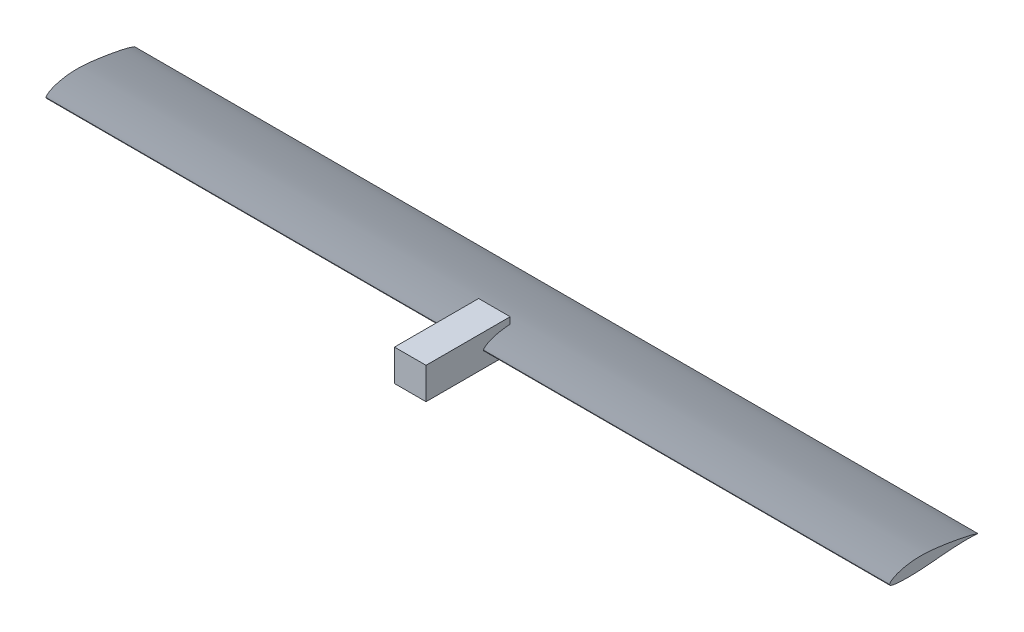
from build123d import *

# Parameters (mm, degrees)
SKETCH1_W                = 76.2
SKETCH1_H                = 76.2
BOSS_EXTRUDE1_DEPTH      = 203.2
BOSS_EXTRUDE2_DEPTH      = 1018.36
BOSS_EXTRUDE2_DEPTH_BACK = 1018.36


with BuildPart() as part:
    # Sketch1 → Boss-Extrude1 (new body)
    with BuildSketch(Plane.XY):
        Rectangle(SKETCH1_W, SKETCH1_H)
    extrude(amount=BOSS_EXTRUDE1_DEPTH)

    # Sketch2 → Boss-Extrude2 (add, two sides)
    with BuildSketch(Plane(origin=(0, 0, 0), x_dir=(0, 0, -1), z_dir=(1, 0, 0))) as boss_extrude2_sk:
        Polygon((149.24802754, 0), (148.952686983, 0.085020225), (148.631792445, 0.180506309), (148.288851334, 0.285199343), (147.927371061, 0.397840416), (147.550859034, 0.517170619), (147.162822662, 0.641931043), (146.766769355, 0.770862779), (146.366206522, 0.902706918), (145.963768895, 1.036469692), (145.5586005, 1.172217911), (145.148972684, 1.310283525), (144.733156796, 1.450998486), (144.309424185, 1.594694745), (143.876046198, 1.741704252), (143.431294185, 1.89235896), (142.973439493, 2.04699082), (142.501047842, 2.205819392), (142.01386244, 2.368614676), (141.511920867, 2.535034284), (140.995260701, 2.704735825), (140.463919523, 2.877376908), (139.917934911, 3.052615144), (139.357344445, 3.230108144), (138.782185705, 3.409513517), (138.192477479, 3.590527148), (137.5881634, 3.772998024), (136.969168307, 3.956813407), (136.335417043, 4.141860559), (135.686834449, 4.328026741), (135.023345366, 4.515199216), (134.344874635, 4.703265244), (133.651347097, 4.892112089), (132.942711254, 5.081653457), (132.219010254, 5.271908833), (131.480310905, 5.462924148), (130.726680013, 5.654745331), (129.958184387, 5.847418315), (129.174890835, 6.040989027), (128.376866163, 6.2355034), (127.564177181, 6.431007364), (126.73691227, 6.627538497), (125.895246103, 6.825100975), (125.039374929, 7.023690624), (124.169494995, 7.223303266), (123.28580255, 7.423934728), (122.388493841, 7.625580833), (121.477765117, 7.828237406), (120.553812625, 8.031900271), (119.616834005, 8.236558294), (118.667032464, 8.442172504), (117.7046126, 8.648696969), (116.729779013, 8.856085761), (115.742736302, 9.064292948), (114.743689066, 9.2732726), (113.732841902, 9.482978787), (112.710399411, 9.693365579), (111.676567583, 9.904385652), (110.631557976, 10.115986118), (109.575583539, 10.328112696), (108.508857223, 10.540711104), (107.431591977, 10.75372706), (106.344000752, 10.967106284), (105.246296497, 11.180794494), (104.138692162, 11.394737409), (103.021402784, 11.608879355), (101.894651753, 11.823159092), (100.758664544, 12.037513988), (99.613666633, 12.25188141), (98.459883498, 12.466198727), (97.297540614, 12.680403306), (96.126863458, 12.894432513), (94.948077505, 13.108223719), (93.761411017, 13.321713593), (92.567103387, 13.534836024), (91.365396794, 13.747524205), (90.156533416, 13.959711327), (88.940755431, 14.171330583), (87.718305017, 14.382315165), (86.489424354, 14.592598265), (85.254355618, 14.802113076), (84.013340989, 15.010792789), (82.766622645, 15.218570597), (81.514442763, 15.425379692), (80.257043522, 15.631153266), (78.994667101, 15.835824511), (77.727555677, 16.03932662), (76.455951429, 16.241592785), (75.180096535, 16.442556197), (73.900234565, 16.642145875), (72.616614657, 16.840274132), (71.32948734, 17.036849108), (70.039103142, 17.231778942), (68.745712594, 17.424971773), (67.449566224, 17.616335741), (66.150914562, 17.805778984), (64.850008137, 17.993209643), (63.547098175, 18.178537945), (62.242438683, 18.361682466), (60.936284366, 18.542563873), (59.62888993, 18.721102832), (58.320510079, 18.897220009), (57.011399518, 19.070836069), (55.701812951, 19.241871677), (54.392005083, 19.410247501), (53.082230619, 19.575875853), (51.772744264, 19.738635647), (50.463800722, 19.89839744), (49.155654698, 20.055031793), (47.848560897, 20.208409267), (46.542774024, 20.35840042), (45.238548783, 20.504875814), (43.936139878, 20.647706007), (42.635790185, 20.78675808), (41.337695254, 20.921885195), (40.042038809, 21.052937034), (38.749004569, 21.179763281), (37.458776256, 21.302213617), (36.171537592, 21.420137725), (34.887472299, 21.533385288), (33.606764097, 21.641805987), (32.329584182, 21.745257856), (31.056053643, 21.843632334), (29.786281042, 21.936829207), (28.520374942, 22.024748264), (27.258443906, 22.107289294), (26.000596496, 22.184352085), (24.746941275, 22.255836425), (23.497586806, 22.321642102), (22.252643044, 22.381677257), (21.012225509, 22.435883431), (19.776451117, 22.484210519), (18.545436779, 22.526608416), (17.319299411, 22.563027015), (16.098155925, 22.59341621), (14.882123235, 22.617725896), (13.671318256, 22.635905967), (12.46585442, 22.647913276), (11.265831244, 22.653732514), (10.071344764, 22.653355328), (8.882491016, 22.646773368), (7.699366037, 22.633978284), (6.522065862, 22.614961724), (5.350686528, 22.589715337), (4.185324071, 22.558230772), (3.026074527, 22.520502462), (1.873033932, 22.476535974), (0.726298323, 22.426339659), (-0.414036264, 22.369921869), (-1.547873793, 22.307290953), (-2.675118228, 22.238455264), (-3.795673532, 22.163423152), (-4.90944367, 22.082202967), (-6.016336781, 21.994812805), (-7.116277705, 21.90130973), (-8.20919546, 21.801760549), (-9.295019063, 21.69623207), (-10.373677529, 21.584791102), (-11.445099876, 21.467504451), (-12.509215121, 21.344438927), (-13.56595228, 21.215661336), (-14.615234802, 21.081246141), (-15.656963869, 20.941298426), (-16.691035092, 20.795930929), (-17.717344084, 20.645256387), (-18.735786458, 20.48938754), (-19.746257828, 20.328437125), (-20.748653805, 20.16251788), (-21.742870003, 19.991742543), (-22.728793684, 19.816223853), (-23.706278705, 19.636074548), (-24.675170573, 19.451407365), (-25.635314796, 19.262335044), (-26.58655688, 19.068970322), (-27.528742333, 18.871425937), (-28.461716661, 18.669814628), (-29.385325371, 18.464249132), (-30.299418147, 18.254837317), (-31.203861371, 18.041667564), (-32.098525604, 17.824823381), (-32.983281407, 17.60438828), (-33.857999338, 17.38044577), (-34.722549958, 17.15307936), (-35.576803827, 16.92237256), (-36.420631504, 16.688408881), (-37.253904246, 16.451272527), (-38.076496092, 16.211050488), (-38.888281777, 15.967830449), (-39.689136036, 15.721700096), (-40.478933606, 15.472747114), (-41.257549221, 15.221059187), (-42.024857617, 14.966724002), (-42.780733529, 14.709829243), (-43.525056564, 14.450463987), (-44.257725814, 14.188722879), (-44.978645244, 13.924701955), (-45.687718816, 13.658497252), (-46.384850496, 13.390204805), (-47.069944245, 13.11992065), (-47.742904029, 12.847740824), (-48.403633812, 12.573761364), (-49.052039644, 12.298079), (-49.688035928, 12.02079325), (-50.311539154, 11.742004324), (-50.922465814, 11.461812434), (-51.520732396, 11.180317793), (-52.106255392, 10.897620611), (-52.678951291, 10.6138211), (-53.238736583, 10.329019473), (-53.785529848, 10.043318724), (-54.319258013, 9.756832983), (-54.839850096, 9.469679165), (-55.347235112, 9.181974182), (-55.84134208, 8.893834948), (-56.322100015, 8.605378378), (-56.789437935, 8.316721384), (-57.243284855, 8.02798088), (-57.683574665, 7.739277956), (-58.110260737, 7.450750402), (-58.523301318, 7.162540186), (-58.922654652, 6.874789272), (-59.308278984, 6.587639629), (-59.680132559, 6.301233223), (-60.038173623, 6.01571202), (-60.38236042, 5.731217987), (-60.712651196, 5.447900049), (-61.029004197, 5.165934969), (-61.331377666, 4.885506469), (-61.619729849, 4.606798269), (-61.894018992, 4.329994091), (-62.154203339, 4.055277657), (-62.400241135, 3.782832688), (-62.632090627, 3.512842905), (-62.849702403, 3.245517779), (-63.052996433, 2.981169776), (-63.241885033, 2.720137109), (-63.416280517, 2.462757993), (-63.5760952, 2.209370643), (-63.721241396, 1.960313274), (-63.851631421, 1.715924099), (-63.967177589, 1.476541333), (-64.067710793, 1.242448213), (-64.152736238, 1.013708068), (-64.221677707, 0.790329248), (-64.273958981, 0.572320105), (-64.309003845, 0.359688989), (-64.32623608, 0.152444252), (-64.32507947, -0.049405756), (-64.304957798, -0.245852683), (-64.265366524, -0.436955683), (-64.206087829, -0.623043923), (-64.12697557, -0.804514074), (-64.027883605, -0.981762808), (-63.908665792, -1.155186795), (-63.769175989, -1.325182707), (-63.609268053, -1.492147216), (-63.428795844, -1.656476992), (-63.227705079, -1.818510251), (-63.006308919, -1.978351378), (-62.765012389, -2.136046305), (-62.504220508, -2.291640963), (-62.2243383, -2.44518128), (-61.925770788, -2.596713188), (-61.608922992, -2.746282618), (-61.274199937, -2.893935498), (-60.921950273, -3.039694795), (-60.55229718, -3.183491614), (-60.165307464, -3.325234092), (-59.761047933, -3.46483037), (-59.339585394, -3.602188587), (-58.900986657, -3.737216883), (-58.445318528, -3.869823395), (-57.972647816, -3.999916265), (-57.483041327, -4.127414765), (-56.976565871, -4.252282708), (-56.453288254, -4.374495041), (-55.913275285, -4.494026712), (-55.356593771, -4.610852667), (-54.78331052, -4.724947853), (-54.19349234, -4.836287218), (-53.587206039, -4.944845708), (-52.964524687, -5.050602447), (-52.325546409, -5.153553258), (-51.670375592, -5.253698142), (-50.999116623, -5.351037098), (-50.311873889, -5.445570127), (-49.608751778, -5.537297229), (-48.889854676, -5.626218403), (-48.155286971, -5.71233365), (-47.405156529, -5.795641578), (-46.639585136, -5.876135227), (-45.858698056, -5.953806248), (-45.062620554, -6.028646287), (-44.251477894, -6.100646996), (-43.425395341, -6.169800022), (-42.584498159, -6.236097015), (-41.728911614, -6.299529624), (-40.858765841, -6.360092978), (-39.974210462, -6.417796122), (-39.07539997, -6.472651585), (-38.162488858, -6.524671891), (-37.235631619, -6.573869569), (-36.294982745, -6.620257143), (-35.340696731, -6.663847141), (-34.372928068, -6.704652089), (-33.39183473, -6.742684514), (-32.397588608, -6.777956942), (-31.390365072, -6.810481899), (-30.370339492, -6.840271912), (-29.337687239, -6.867339507), (-28.292583683, -6.891697212), (-27.235204195, -6.913357551), (-26.165724145, -6.932333053), (-25.084323079, -6.948632763), (-23.991197246, -6.96225181), (-22.886547068, -6.973181843), (-21.770572969, -6.981414512), (-20.643475372, -6.986941465), (-19.5054547, -6.989754352), (-18.356711378, -6.989844821), (-17.197445828, -6.987204521), (-16.027863345, -6.981827885), (-14.84818871, -6.973720481), (-13.658651574, -6.962890659), (-12.459481589, -6.949346771), (-11.250908408, -6.933097167), (-10.033161681, -6.914150198), (-8.80647106, -6.892514215), (-7.571066198, -6.86819757), (-6.327178138, -6.841196086), (-5.07504349, -6.811455483), (-3.814900259, -6.778908953), (-2.546986445, -6.743489687), (-1.271540053, -6.705130879), (0.011200915, -6.663765719), (1.300998456, -6.619327401), (2.597614568, -6.571749117), (3.900832821, -6.52095362), (5.210523079, -6.466821909), (6.52657678, -6.409224543), (7.84888536, -6.348032083), (9.177340258, -6.283115088), (10.511832909, -6.214344119), (11.852254753, -6.141589735), (13.198497226, -6.064722496), (14.550474034, -5.98364915), (15.908187962, -5.898421194), (17.271664061, -5.809126314), (18.640927387, -5.715852194), (20.01600299, -5.61868652), (21.396915924, -5.517716978), (22.783691242, -5.413031252), (24.176353997, -5.304717027), (25.574898622, -5.192893306), (26.979197068, -5.077804354), (28.389090667, -4.959725753), (29.80442075, -4.838933085), (31.225028648, -4.715701933), (32.650755694, -4.590307878), (34.081443219, -4.463026504), (35.516932554, -4.334133391), (36.957036498, -4.203892292), (38.40145372, -4.072519635), (39.849854358, -3.940220021), (41.301908546, -3.807198047), (42.757286422, -3.673658313), (44.215658122, -3.539805418), (45.676693784, -3.405843959), (47.140063542, -3.271978537), (48.605436143, -3.138399136), (50.072474763, -3.005237284), (51.540841187, -2.872609894), (53.010197203, -2.740633879), (54.480204594, -2.609426155), (55.950525147, -2.479103634), (57.420820647, -2.349783229), (58.890752879, -2.221581856), (60.359980846, -2.094612946), (61.828152415, -1.968976018), (63.294912669, -1.844767106), (64.759906692, -1.722082246), (66.222779568, -1.601017476), (67.683176379, -1.481668831), (69.140742211, -1.364132347), (70.595122145, -1.248504061), (72.045964747, -1.134873746), (73.492932496, -1.023306121), (74.935691354, -0.913859644), (76.373907282, -0.806592771), (77.807246241, -0.701563959), (79.235374192, -0.598831665), (80.657957096, -0.498454346), (82.074660914, -0.400490458), (83.48514952, -0.304996371), (84.889078435, -0.212020103), (86.286101095, -0.121607584), (87.675870933, -0.033804744), (89.058041385, 0.051342486), (90.432265885, 0.133788176), (91.798197867, 0.213486395), (93.155490767, 0.290391213), (94.503802193, 0.364461571), (95.842806459, 0.435675896), (97.172182051, 0.504017486), (98.491607457, 0.569469639), (99.800761165, 0.632015653), (101.099321663, 0.691638826), (102.386967436, 0.748322456), (103.663376974, 0.802049841), (104.928230155, 0.852807063), (106.181212426, 0.900591337), (107.422010626, 0.945402666), (108.650311593, 0.987241047), (109.865802165, 1.026106481), (111.068169181, 1.061998969), (112.25709948, 1.094918509), (113.432279899, 1.124865103), (114.593399365, 1.151842926), (115.740155155, 1.175872854), (116.872246635, 1.196979942), (117.989373169, 1.215189241), (119.091234121, 1.230525805), (120.177528858, 1.243014688), (121.247956743, 1.25268094), (122.302217142, 1.259549617), (123.340012204, 1.263647161), (124.361055211, 1.265005586), (125.36506223, 1.263658296), (126.351749329, 1.259638694), (127.320832574, 1.252980184), (128.272028032, 1.243716169), (129.20505177, 1.231880055), (130.119619855, 1.217505245), (131.015449745, 1.200636973), (131.892264467, 1.181367795), (132.749788438, 1.1598021), (133.587746076, 1.136044274), (134.4058618, 1.110198705), (135.203860026, 1.082369779), (135.981465173, 1.052661883), (136.738401659, 1.021179406), (137.474405036, 0.988035085), (138.189255395, 0.953375062), (138.882743962, 0.917353831), (139.554661962, 0.880125883), (140.204800621, 0.841845713), (140.832951165, 0.802667813), (141.438904819, 0.762746676), (142.022452809, 0.722236796), (142.58378164, 0.68125091), (143.124658935, 0.639734737), (143.647247596, 0.597592241), (144.153710526, 0.554727386), (144.646210627, 0.511044135), (145.126910802, 0.466446453), (145.597973952, 0.420838303), (146.06156298, 0.374123648), (146.518839367, 0.32630597), (146.966958911, 0.277786809), (147.402075988, 0.229067225), (147.820344974, 0.180648276), (148.217920246, 0.133031021), (148.590956181, 0.086716517), (148.935607153, 0.042205824), align=None)
    extrude(amount=BOSS_EXTRUDE2_DEPTH)
    extrude(boss_extrude2_sk.sketch, amount=-BOSS_EXTRUDE2_DEPTH_BACK)


solid = part.part
